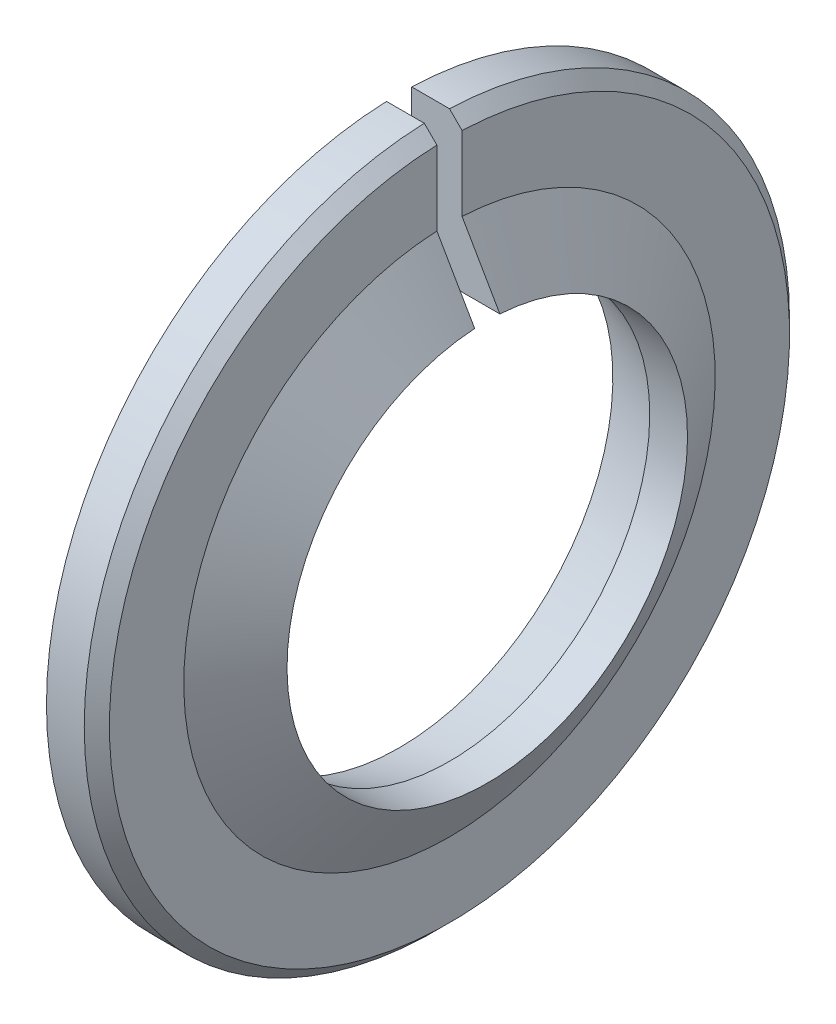
from build123d import *

# Parameters (mm, degrees)
CHAMFER_1_SIZE      = 0.5
SKETCH_2_W          = 1
SKETCH_2_H          = 14.5
CUT_EXTRUDE_2_DEPTH = 4.5


with BuildPart() as part:
    # Эскиз1 → Повернуть1 (revolve)
    with BuildSketch(Plane.XY):
        Polygon((0, 7.95), (1.5, 7.95), (0, 10.548076211), (0, 14), (-2, 14), (-2, 8.485898385), align=None)
    revolve(axis=Axis((-6.176798117, 0, 0), (1, 0, 0)))

    # Фаска1
    chamfer_1_edges = [part.edges().sort_by_distance(p)[0] for p in [
        (0, -14, 0),
    ]]
    chamfer(chamfer_1_edges, length=CHAMFER_1_SIZE)

    # Эскиз2 → Вырез-Вытянуть2 (cut, through all)
    with BuildSketch(Plane.ZY.offset(2)):
        with Locations((0, 7.25)):
            Rectangle(SKETCH_2_W, SKETCH_2_H)
    extrude(amount=-CUT_EXTRUDE_2_DEPTH, mode=Mode.SUBTRACT)


solid = part.part
